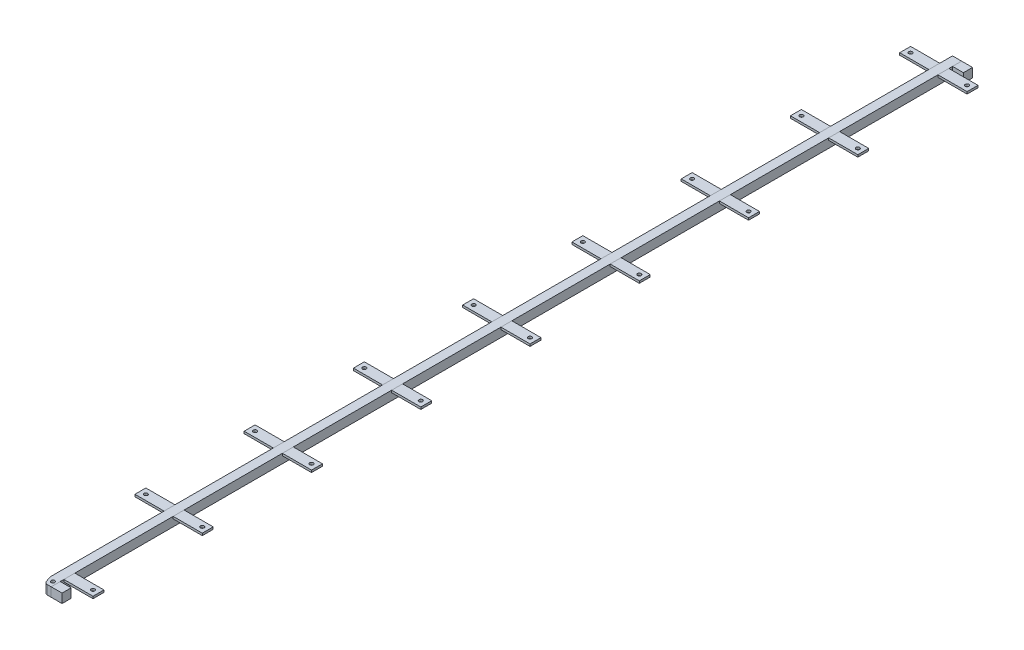
from build123d import *

# Parameters (mm, degrees)
SKETCH_1_W             = 25
SKETCH_1_H             = 2500
EXTRUDE_1_DEPTH        = 25
SKETCH_2_W             = 30
SKETCH_2_H             = 25
EXTRUDE_2_DEPTH        = 25
CHAMFER_1_SIZE         = 22
CHAMFER_1_SIZE2        = 8
FILLET_2_R             = 10
SKETCH_3_W             = 30
SKETCH_3_H             = 25
EXTRUDE_3_DEPTH        = 25
SKETCH_4_W             = 80
SKETCH_4_H             = 30
SKETCH_4_R             = 5
EXTRUDE_4_DEPTH        = 6
EXTRUDE_4_2_DEPTH      = 6
PATTERN_LINEAR_1_COUNT = 9
PATTERN_LINEAR_1_PITCH = 300
SKETCH_5_R             = 5
CUT_EXTRUDE_3_DEPTH    = 25
SKETCH_6_W             = 80
SKETCH_6_H             = 30
CUT_EXTRUDE_4_DEPTH    = 10


with BuildPart() as part:
    # 草图1 → 凸台-拉伸1 (new body)
    with BuildSketch(Plane(origin=(0, 0, 0), x_dir=(1, 0, 0), z_dir=(0, 1, 0))):
        with Locations((12.5, 1250)):
            Rectangle(SKETCH_1_W, SKETCH_1_H)
    extrude(amount=EXTRUDE_1_DEPTH)

    # 倒角1
    chamfer_1_edges = [part.edges().sort_by_distance(p)[0] for p in [
        (0, 12.5, 0),
    ]]
    chamfer_1_side = [part.faces().sort_by_distance(p)[0] for p in [
        (0, 12.5, -1250),
    ]]
    chamfer(chamfer_1_edges, length=CHAMFER_1_SIZE, length2=CHAMFER_1_SIZE2, reference=chamfer_1_side[0])

    # 圆角2
    fillet_2_edges = [part.edges().sort_by_distance(p)[0] for p in [
        (8, 12.5, 0),
        (0, 12.5, -22),
    ]]
    fillet(fillet_2_edges, radius=FILLET_2_R)

    # 草图5 → 切除-拉伸3 (cut)
    with BuildSketch(Plane.XZ):
        with Locations((15, -15)):
            Circle(SKETCH_5_R)
    extrude(amount=-CUT_EXTRUDE_3_DEPTH, mode=Mode.SUBTRACT)


with BuildPart() as body_2:
    # 草图2 → 凸台-拉伸2 (new body)
    with BuildSketch(Plane(origin=(0, 0, 0), x_dir=(1, 0, 0), z_dir=(0, 1, 0))):
        with Locations((40, 12.5)):
            Rectangle(SKETCH_2_W, SKETCH_2_H)
    extrude(amount=EXTRUDE_2_DEPTH)


with BuildPart() as body_3:
    # 草图3 → 凸台-拉伸3 (new body)
    with BuildSketch(Plane(origin=(0, 0, -2500), x_dir=(-1, 0, 0), z_dir=(0, 0, -1))):
        with Locations((-40, 12.5)):
            Rectangle(SKETCH_3_W, SKETCH_3_H)
    extrude(amount=-EXTRUDE_3_DEPTH)


with BuildPart() as body_4:
    # 草图4 → 凸台-拉伸4 (new body)
    with BuildSketch(Plane(origin=(0, 25, 0), x_dir=(1, 0, 0), z_dir=(0, 1, 0))):
        with Locations((-40, 2450)):
            Rectangle(SKETCH_4_W, SKETCH_4_H)
        with Locations((-65, 2450)):
            Circle(SKETCH_4_R, mode=Mode.SUBTRACT)
    extrude_4 = extrude(amount=-EXTRUDE_4_DEPTH)


with BuildPart() as body_5:
    # 草图4 → Extrude 4 2 (new body)
    with BuildSketch(Plane(origin=(0, 25, 0), x_dir=(1, 0, 0), z_dir=(0, 1, 0))):
        with Locations((65, 2450)):
            Rectangle(SKETCH_4_W, SKETCH_4_H)
        with Locations((90, 2450)):
            Circle(SKETCH_4_R, mode=Mode.SUBTRACT)
    extrude_4_2 = extrude(amount=-EXTRUDE_4_2_DEPTH)


with BuildPart() as pattern_linear_1_1:
    # 阵列(线性)1: pattern copy
    add(extrude_4.moved(Location(Vector(0, 0, 1) * (1 * PATTERN_LINEAR_1_PITCH))))


with BuildPart() as pattern_linear_1_2:
    # 阵列(线性)1: pattern copy
    add(extrude_4.moved(Location(Vector(0, 0, 1) * (2 * PATTERN_LINEAR_1_PITCH))))


with BuildPart() as pattern_linear_1_3:
    # 阵列(线性)1: pattern copy
    add(extrude_4.moved(Location(Vector(0, 0, 1) * (3 * PATTERN_LINEAR_1_PITCH))))


with BuildPart() as pattern_linear_1_4:
    # 阵列(线性)1: pattern copy
    add(extrude_4.moved(Location(Vector(0, 0, 1) * (4 * PATTERN_LINEAR_1_PITCH))))


with BuildPart() as pattern_linear_1_5:
    # 阵列(线性)1: pattern copy
    add(extrude_4.moved(Location(Vector(0, 0, 1) * (5 * PATTERN_LINEAR_1_PITCH))))


with BuildPart() as pattern_linear_1_6:
    # 阵列(线性)1: pattern copy
    add(extrude_4.moved(Location(Vector(0, 0, 1) * (6 * PATTERN_LINEAR_1_PITCH))))


with BuildPart() as pattern_linear_1_7:
    # 阵列(线性)1: pattern copy
    add(extrude_4.moved(Location(Vector(0, 0, 1) * (7 * PATTERN_LINEAR_1_PITCH))))


with BuildPart() as pattern_linear_1_8:
    # 阵列(线性)1: pattern copy
    add(extrude_4.moved(Location(Vector(0, 0, 1) * (8 * PATTERN_LINEAR_1_PITCH))))

    # 草图6 → 切除-拉伸4 (cut)
    with BuildSketch(Plane(origin=(0, 19, 0), x_dir=(-1, 0, 0), z_dir=(0, -1, 0))):
        with Locations((40, 50)):
            Rectangle(SKETCH_6_W, SKETCH_6_H)
    extrude(amount=-CUT_EXTRUDE_4_DEPTH, mode=Mode.SUBTRACT)


with BuildPart() as pattern_linear_1_9:
    # 阵列(线性)1: pattern copy
    add(extrude_4_2.moved(Location(Vector(0, 0, 1) * (1 * PATTERN_LINEAR_1_PITCH))))


with BuildPart() as pattern_linear_1_10:
    # 阵列(线性)1: pattern copy
    add(extrude_4_2.moved(Location(Vector(0, 0, 1) * (2 * PATTERN_LINEAR_1_PITCH))))


with BuildPart() as pattern_linear_1_11:
    # 阵列(线性)1: pattern copy
    add(extrude_4_2.moved(Location(Vector(0, 0, 1) * (3 * PATTERN_LINEAR_1_PITCH))))


with BuildPart() as pattern_linear_1_12:
    # 阵列(线性)1: pattern copy
    add(extrude_4_2.moved(Location(Vector(0, 0, 1) * (4 * PATTERN_LINEAR_1_PITCH))))


with BuildPart() as pattern_linear_1_13:
    # 阵列(线性)1: pattern copy
    add(extrude_4_2.moved(Location(Vector(0, 0, 1) * (5 * PATTERN_LINEAR_1_PITCH))))


with BuildPart() as pattern_linear_1_14:
    # 阵列(线性)1: pattern copy
    add(extrude_4_2.moved(Location(Vector(0, 0, 1) * (6 * PATTERN_LINEAR_1_PITCH))))


with BuildPart() as pattern_linear_1_15:
    # 阵列(线性)1: pattern copy
    add(extrude_4_2.moved(Location(Vector(0, 0, 1) * (7 * PATTERN_LINEAR_1_PITCH))))


with BuildPart() as pattern_linear_1_16:
    # 阵列(线性)1: pattern copy
    add(extrude_4_2.moved(Location(Vector(0, 0, 1) * (8 * PATTERN_LINEAR_1_PITCH))))


solid = Compound([part.part, body_2.part, body_3.part, body_4.part, body_5.part, pattern_linear_1_1.part, pattern_linear_1_2.part, pattern_linear_1_3.part, pattern_linear_1_4.part, pattern_linear_1_5.part, pattern_linear_1_6.part, pattern_linear_1_7.part, pattern_linear_1_9.part, pattern_linear_1_10.part, pattern_linear_1_11.part, pattern_linear_1_12.part, pattern_linear_1_13.part, pattern_linear_1_14.part, pattern_linear_1_15.part, pattern_linear_1_16.part])
